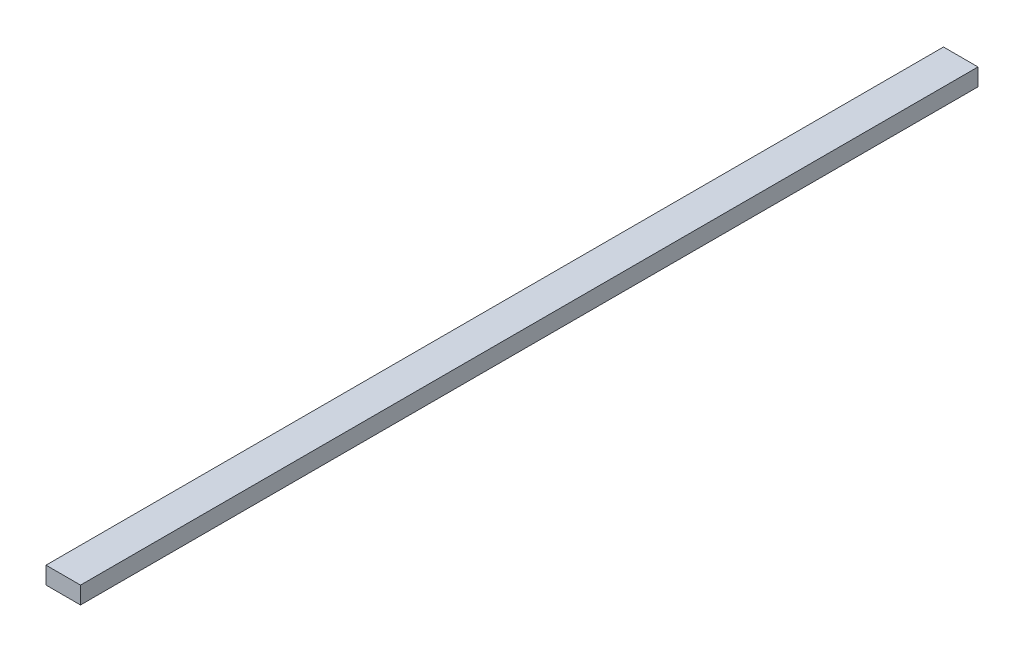
from build123d import *

# Parameters (mm, degrees)
SKETCH_1_W      = 80
SKETCH_1_H      = 40
EXTRUDE_1_DEPTH = 2080


with BuildPart() as part:
    # Эскиз1 → Бобышка-Вытянуть1 (new body)
    with BuildSketch(Plane.XY):
        with Locations((16.090225564, 2.631578947)):
            Rectangle(SKETCH_1_W, SKETCH_1_H)
    extrude(amount=EXTRUDE_1_DEPTH)


solid = part.part
